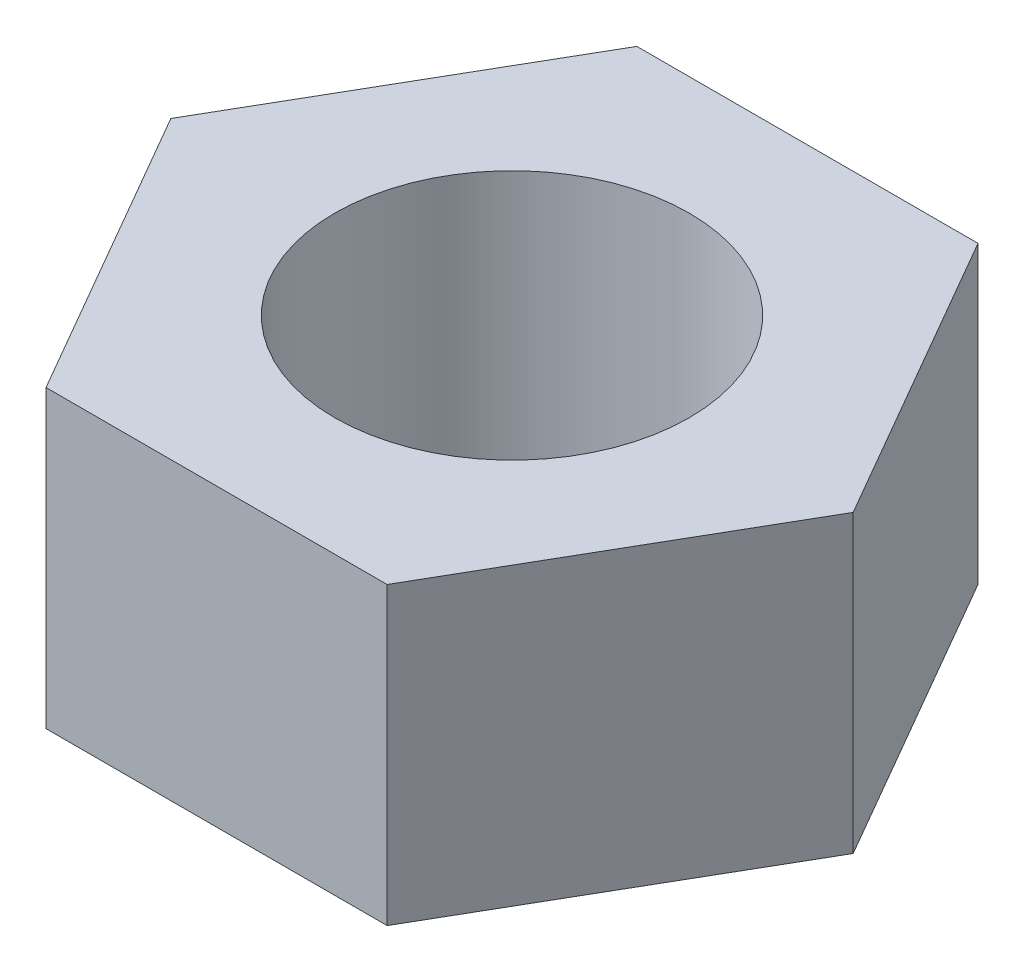
from build123d import *

# Parameters (mm, degrees)
BOLT_HEAD_DEPTH    = 5
SKETCH2_2_R        = 3
CUT_EXTRUDE1_DEPTH = 10.128709292


with BuildPart() as part:
    # Sketch1 → Bolt head (new body)
    with BuildSketch(Plane(origin=(0, 0, 0), x_dir=(1, 0, 0), z_dir=(0, 1, 0))):
        Polygon((5.773502692, 0), (2.886751346, 5), (-2.886751346, 5), (-5.773502692, 0), (-2.886751346, -5), (2.886751346, -5), align=None)
    extrude(amount=BOLT_HEAD_DEPTH)

    # Sketch2_2 → Cut-Extrude1 (cut, through all)
    with BuildSketch(Plane(origin=(0, 0, 0), x_dir=(1, 0, 0), z_dir=(0, 1, 0))):
        Circle(SKETCH2_2_R)
    extrude(amount=CUT_EXTRUDE1_DEPTH, mode=Mode.SUBTRACT)


solid = part.part
